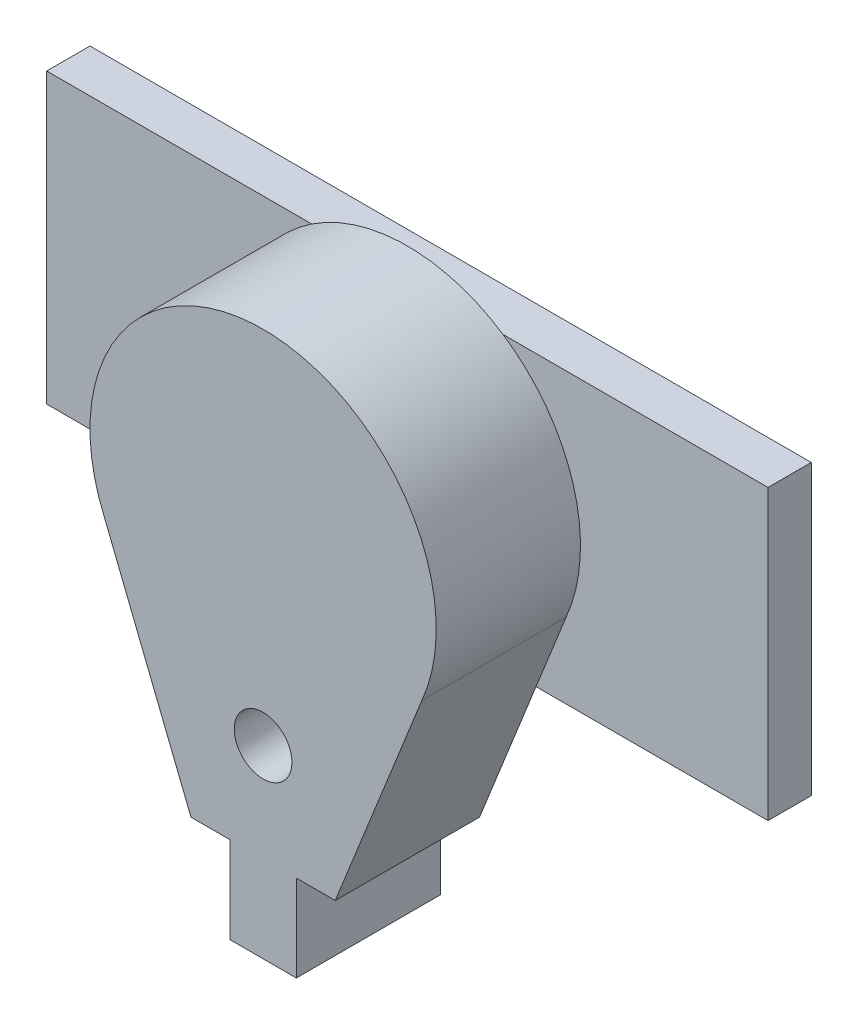
from build123d import *

# Parameters (mm, degrees)
BOSS_EXTRU_1_DEPTH      = 10
ESQUISSE2_R             = 2
ENL_V_MAT_EXTRU_1_DEPTH = 10
ESQUISSE4_W             = 4.610591942
ESQUISSE4_H             = 10
BOSS_EXTRU_3_DEPTH      = 6
ESQUISSE3_W             = 50
ESQUISSE3_H             = 20
BOSS_EXTRU_2_DEPTH      = 3


with BuildPart() as part:
    # Esquisse1 → Boss.-Extru.1 (new body)
    with BuildSketch(Plane.XY):
        with BuildLine():
            Line((-11, -4.795831523), (-5, -19.795831523))
            Line((-5, -19.795831523), (5, -19.795831523))
            Line((5, -19.795831523), (11, -4.795831523))
            ThreePointArc((11, -4.795831523), (0, 12), (-11, -4.795831523))
        make_face()
    extrude(amount=BOSS_EXTRU_1_DEPTH)

    # Esquisse2 → Enlèv. mat.-Extru.1 (cut)
    with BuildSketch(Plane(origin=(0, 0, 0), x_dir=(-1, 0, 0), z_dir=(0, 0, -1))):
        with Locations((0, -13)):
            Circle(ESQUISSE2_R)
    extrude(amount=-ENL_V_MAT_EXTRU_1_DEPTH, mode=Mode.SUBTRACT)

    # Esquisse4 → Boss.-Extru.3 (add)
    with BuildSketch(Plane(origin=(0, -19.795831523, 0), x_dir=(-1, 0, 0), z_dir=(0, -1, 0))):
        with Locations((0, -5)):
            Rectangle(ESQUISSE4_W, ESQUISSE4_H)
    extrude(amount=BOSS_EXTRU_3_DEPTH)

    # Esquisse3 → Boss.-Extru.2 (add)
    with BuildSketch(Plane(origin=(0, 0, 0), x_dir=(-1, 0, 0), z_dir=(0, 0, -1))):
        Rectangle(ESQUISSE3_W, ESQUISSE3_H)
    extrude(amount=BOSS_EXTRU_2_DEPTH)


solid = part.part
